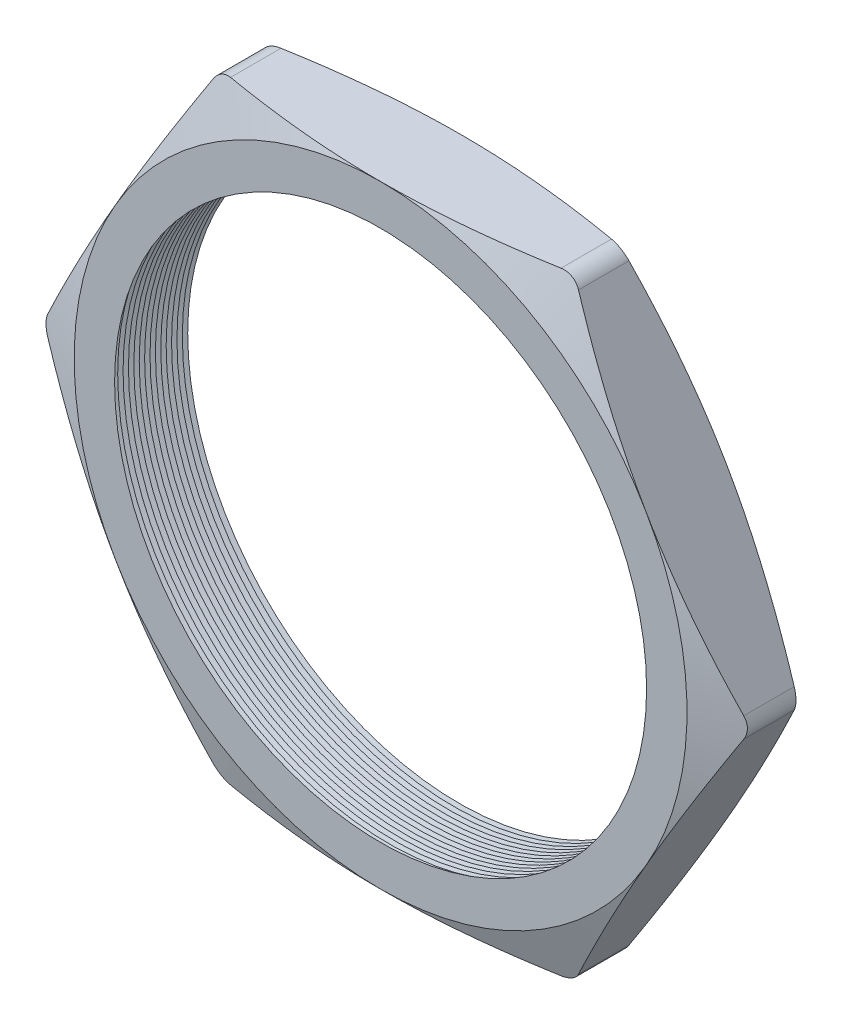
from build123d import *

# Parameters (mm, degrees)
SKETCH1_R          = 10.033
EXTRUDE1_DEPTH     = 3.048
FILLET1_R          = 0.762
SKETCH2_OUTSIDE_W  = 57.75
SKETCH2_OUTSIDE_H  = 54.41
SKETCH2_OUTSIDE_R  = 11.557
CUT_EXTRUDE1_DEPTH = 4.048
CUT_EXTRUDE1_DRAFT = -70
SKETCH3_OUTSIDE_W  = 57.75
SKETCH3_OUTSIDE_H  = 54.41
SKETCH3_OUTSIDE_R  = 11.557
CUT_EXTRUDE2_DEPTH = 4.0480001
CUT_EXTRUDE2_DRAFT = -70
LPATTERN1_COUNT    = 15
LPATTERN1_PITCH    = 0.2032


with BuildPart() as part:
    # Sketch1 → Extrude1 (new body)
    with BuildSketch(Plane.XY):
        Polygon((-13.344874122, 0), (-6.672437061, -11.557), (6.672437061, -11.557), (13.344874122, 0), (6.672437061, 11.557), (-6.672437061, 11.557), align=None)
        Circle(SKETCH1_R, mode=Mode.SUBTRACT)
    extrude(amount=EXTRUDE1_DEPTH)

    # Fillet1
    fillet1_edges = [part.edges().sort_by_distance(p)[0] for p in [
        (13.344874122, 0, 1.524),
        (6.672437061, -11.557, 1.524),
        (-6.672437061, -11.557, 1.524),
        (-13.344874122, 0, 1.524),
        (-6.672437061, 11.557, 1.524),
        (6.672437061, 11.557, 1.524),
    ]]
    fillet(fillet1_edges, radius=FILLET1_R)


with BuildPart() as cut_extrude1_tool:
    # Sketch2 outside → Cut-Extrude1 (with draft: the straight prism first)
    with BuildSketch(Plane.XY.offset(3.048)):
        Rectangle(SKETCH2_OUTSIDE_W, SKETCH2_OUTSIDE_H)
        Circle(SKETCH2_OUTSIDE_R, mode=Mode.SUBTRACT)
    extrude(amount=-CUT_EXTRUDE1_DEPTH)
    # Cut-Extrude1: the draft: its side faces are tilted about the plane it starts from
    cut_extrude1_sides = [cut_extrude1_tool.faces().sort_by_distance(p)[0] for p in [
        (0, -27.205, 1.024),
        (28.875, 0, 1.024),
        (0, 27.205, 1.024),
        (-28.875, 0, 1.024),
        (-11.557, 0, 1.024),
    ]]
    draft(cut_extrude1_sides, Plane.XY.offset(3.048), CUT_EXTRUDE1_DRAFT)


with BuildPart() as part_1:
    add(part.part)

    # Cut-Extrude1: cut by cut_extrude1_tool
    add(cut_extrude1_tool.part, mode=Mode.SUBTRACT)


with BuildPart() as cut_extrude2_tool:
    # Sketch3 outside → Cut-Extrude2 (with draft: the straight prism first)
    with BuildSketch(Plane(origin=(0, 0, 0), x_dir=(-1, 0, 0), z_dir=(0, 0, -1))):
        Rectangle(SKETCH3_OUTSIDE_W, SKETCH3_OUTSIDE_H)
        Circle(SKETCH3_OUTSIDE_R, mode=Mode.SUBTRACT)
    extrude(amount=-CUT_EXTRUDE2_DEPTH)
    # Cut-Extrude2: the draft: its side faces are tilted about the plane it starts from
    cut_extrude2_sides = [cut_extrude2_tool.faces().sort_by_distance(p)[0] for p in [
        (0, -27.205, 2.02400005),
        (-28.875, 0, 2.02400005),
        (0, 27.205, 2.02400005),
        (28.875, 0, 2.02400005),
        (11.557, 0, 2.02400005),
    ]]
    draft(cut_extrude2_sides, Plane(origin=(0, 0, 0), x_dir=(-1, 0, 0), z_dir=(0, 0, -1)), CUT_EXTRUDE2_DRAFT)


with BuildPart() as part_2:
    add(part_1.part)

    # Cut-Extrude2: cut by cut_extrude2_tool
    add(cut_extrude2_tool.part, mode=Mode.SUBTRACT)

    # Sketch4 → Cut-Revolve1 (revolve, cut)
    with BuildSketch(Plane(origin=(0, 0, 0), x_dir=(1, 0, 0), z_dir=(0, 1, 0))):
        Polygon((-10.033, -3.048), (-10.033, -2.608059095), (-10.414, -2.828029547), align=None)
    cut_revolve1 = revolve(axis=Axis((0, 0, 3.048), (0, 0, -1)), mode=Mode.SUBTRACT)

    # LPattern1: Cut-Revolve1 ×15
    with Locations(*[(0, 0, -i * LPATTERN1_PITCH) for i in range(1, LPATTERN1_COUNT)]):
        add(cut_revolve1, mode=Mode.SUBTRACT)


solid = part_2.part
